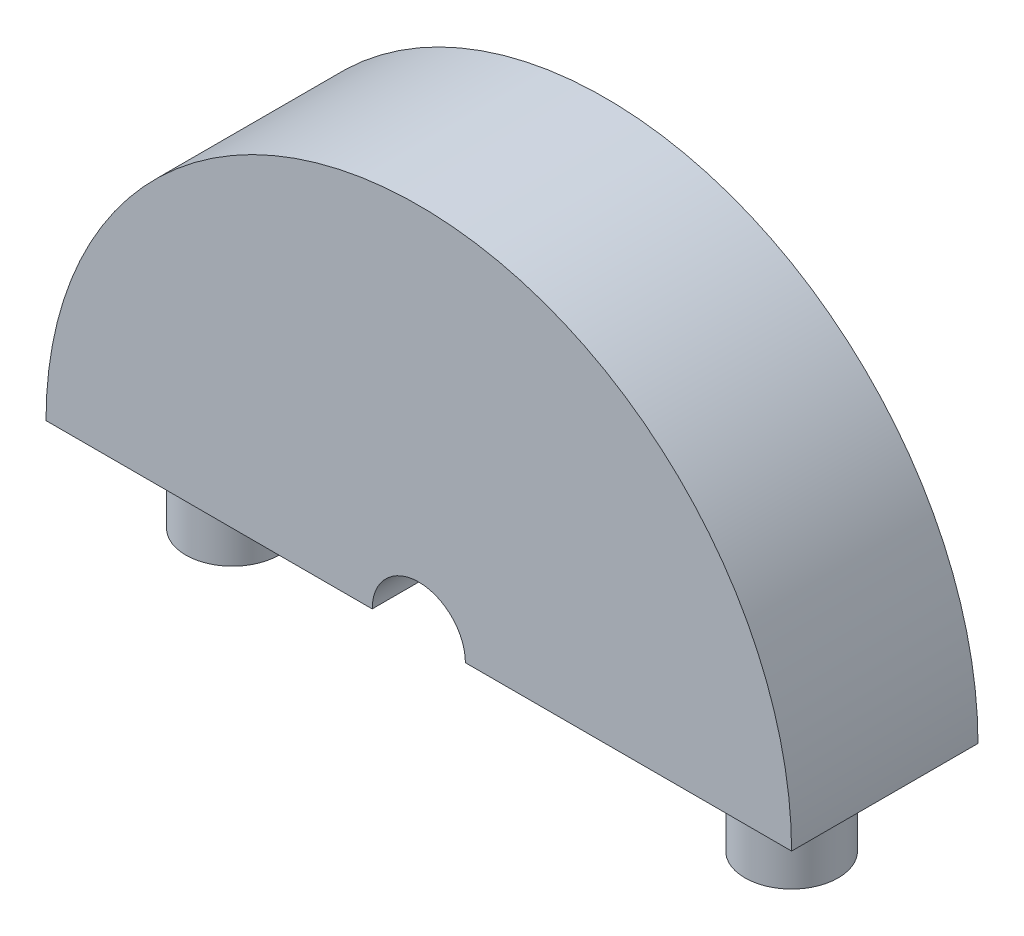
from build123d import *

# Parameters (mm, degrees)
BOSS_EXTRUDE1_DEPTH = 10
SKETCH4_W           = 10
SKETCH4_H           = 2.5
SKETCH5_R           = 2.5
BOSS_EXTRUDE2_DEPTH = 5


with BuildPart() as part:
    # Sketch2 → Boss-Extrude1 (new body)
    with BuildSketch(Plane.XY):
        with BuildLine():
            Line((20, 0), (-20, 0))
            ThreePointArc((-20, 0), (0, 20), (20, 0))
        make_face()
    extrude(amount=BOSS_EXTRUDE1_DEPTH)

    # Sketch4 → Cut-Revolve1 (revolve, cut)
    with BuildSketch(Plane(origin=(0, 0, 0), x_dir=(0, 0, -1), z_dir=(1, 0, 0))):
        with Locations((-5, 1.25)):
            Rectangle(SKETCH4_W, SKETCH4_H)
    revolve(axis=Axis((0, 0, 17.133909945), (0, 0, -1)), mode=Mode.SUBTRACT)

    # Sketch5 → Boss-Extrude2 (add)
    with BuildSketch(Plane.XZ):
        with Locations((-15, 5)):
            Circle(SKETCH5_R)
        with Locations((15, 5)):
            Circle(SKETCH5_R)
    extrude(amount=BOSS_EXTRUDE2_DEPTH)


solid = part.part
